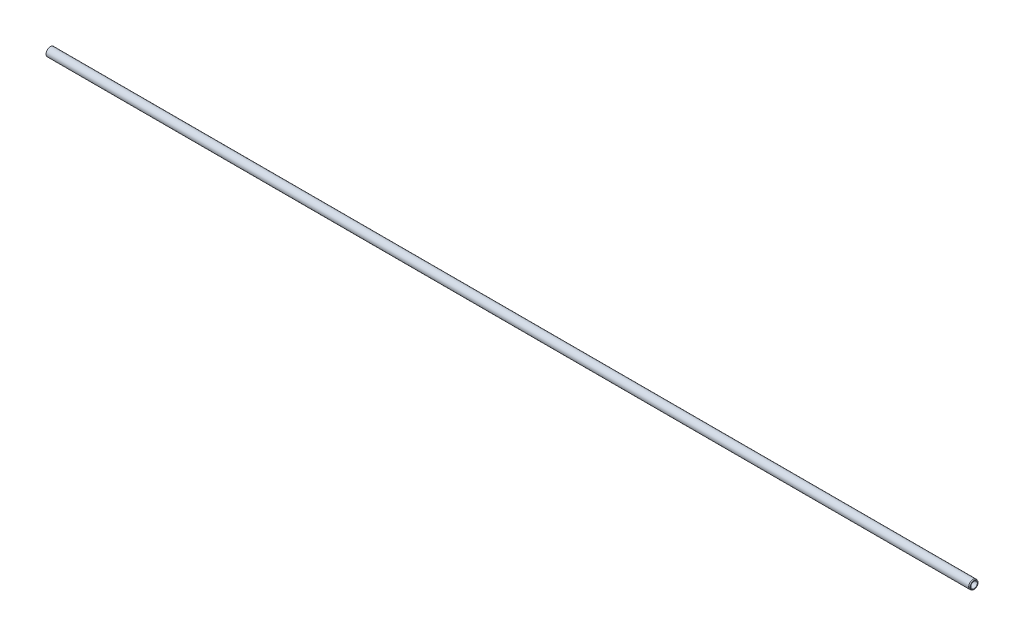
from build123d import *


with BuildPart() as part:
    # Sketch1 → Base-Revolve (revolve)
    with BuildSketch(Plane.XY):
        Polygon((0, 10), (0, 7.5), (2140, 7.5), (2140, 9.090074414), (2137.5, 10), align=None)
    revolve(axis=Axis((0, 0, 0), (1, 0, 0)))


solid = part.part
